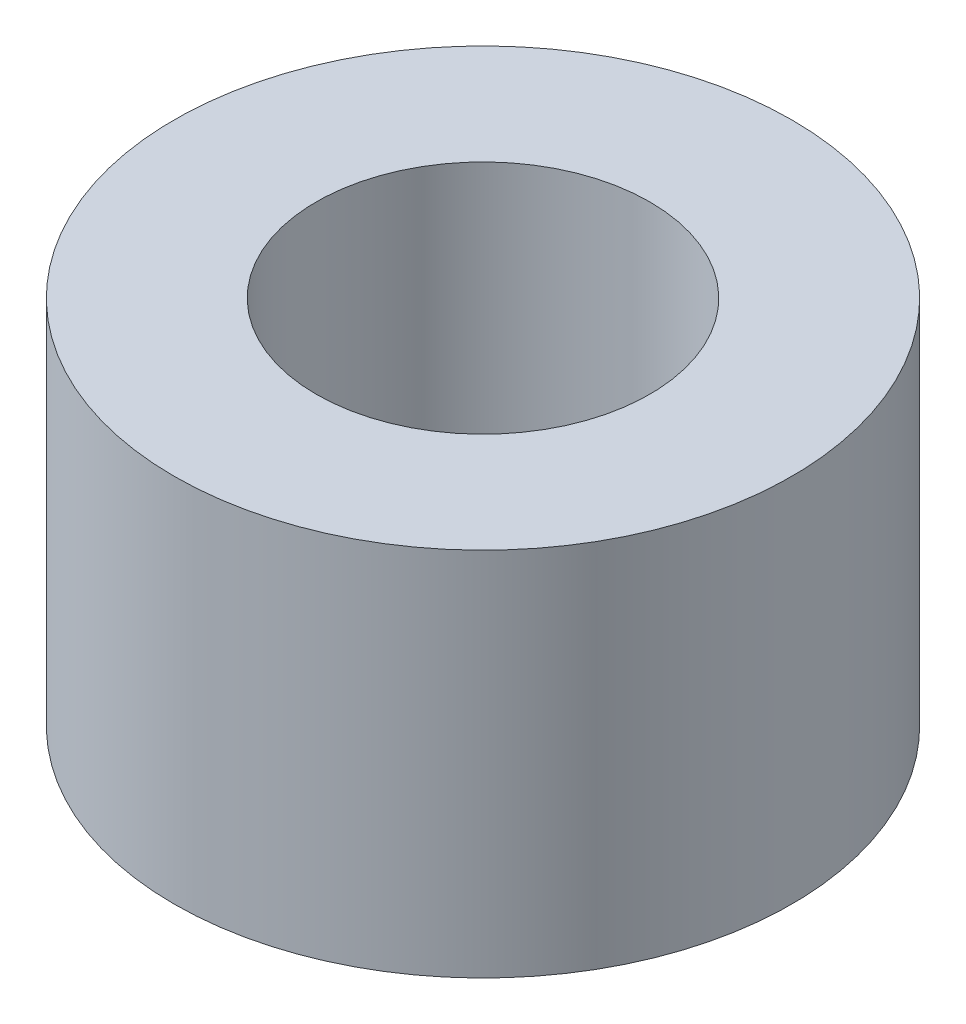
from build123d import *

# Parameters (mm, degrees)
SKETCH1_R           = 5
SKETCH1_R_2         = 2.7
BOSS_EXTRUDE1_DEPTH = 6


with BuildPart() as part:
    # Sketch1 → Boss-Extrude1 (new body)
    with BuildSketch(Plane(origin=(0, 0, 0), x_dir=(1, 0, 0), z_dir=(0, 1, 0))):
        Circle(SKETCH1_R)
        Circle(SKETCH1_R_2, mode=Mode.SUBTRACT)
    extrude(amount=BOSS_EXTRUDE1_DEPTH)


solid = part.part
